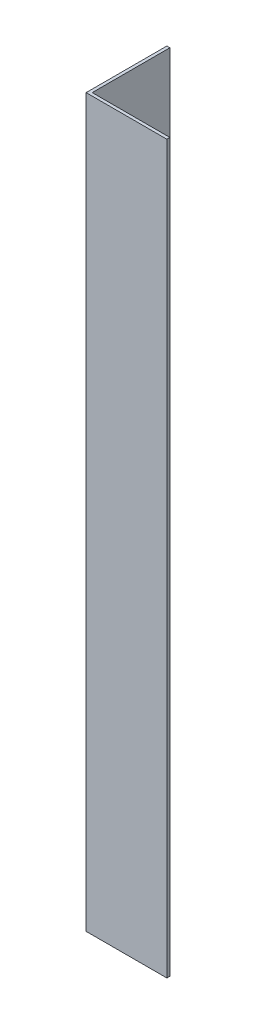
from build123d import *

# Parameters (mm, degrees)
EXTRUDE_1_DEPTH = 180


with BuildPart() as part:
    # Эскиз1 → Бобышка-Вытянуть1 (new body)
    with BuildSketch(Plane(origin=(0, 0, 0), x_dir=(1, 0, 0), z_dir=(0, 1, 0))):
        Polygon((0, 0), (0, 20), (0.75, 20), (0.75, 0.75), (20, 0.75), (20, 0), align=None)
    extrude(amount=EXTRUDE_1_DEPTH)


solid = part.part
